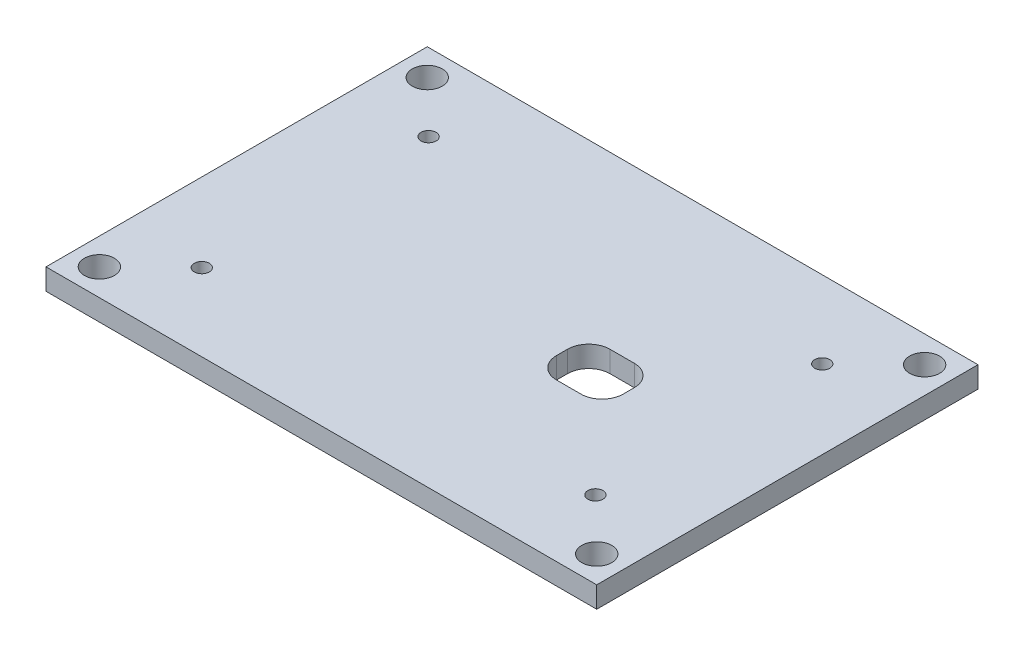
from build123d import *

# Parameters (mm, degrees)
SKETCH1_W             = 82.55
SKETCH1_H             = 57.15
BOSS_EXTRUDE1_DEPTH   = 3.175
CUT_EXTRUDE5_DEPTH    = 10
F_8_CLEARANCE_HOLE1_D = 4.4958
F_4_40_TAPPED_HOLE1_D = 2.2606


with BuildPart() as part:
    # Sketch1 → Boss-Extrude1 (new body)
    with BuildSketch(Plane(origin=(0, 0, 0), x_dir=(1, 0, 0), z_dir=(0, 1, 0))):
        Rectangle(SKETCH1_W, SKETCH1_H)
    extrude(amount=BOSS_EXTRUDE1_DEPTH)

    # Sketch2 → Cut-Extrude5 (cut)
    with BuildSketch(Plane.XZ):
        with BuildLine():
            Line((8.5, 1.825), (8.5, 0.175))
            ThreePointArc((8.5, 0.175), (9.42993597, -2.07006403), (11.675, -3))
            Line((11.675, -3), (15.325, -3))
            ThreePointArc((15.325, -3), (17.57006403, -2.07006403), (18.5, 0.175))
            Line((18.5, 0.175), (18.5, 1.825))
            ThreePointArc((18.5, 1.825), (17.57006403, 4.07006403), (15.325, 5))
            Line((15.325, 5), (11.675, 5))
            ThreePointArc((11.675, 5), (9.42993597, 4.07006403), (8.5, 1.825))
        make_face()
    extrude(amount=-CUT_EXTRUDE5_DEPTH, mode=Mode.SUBTRACT)

    # #8 Clearance Hole1 (through all)
    with Locations(Plane(origin=(0, 0, 0), x_dir=(-1, 0, 0), z_dir=(0, -1, 0))):
        with Locations((-37.275, 24.575), (37.275, 24.575), (37.275, -24.575), (-37.275, -24.575)):
            Hole(F_8_CLEARANCE_HOLE1_D / 2)

    # #4-40 Tapped Hole1 (through all)
    with Locations(Plane(origin=(0, 3.175, 0), x_dir=(1, 0, 0), z_dir=(0, 1, 0))):
        with Locations((-29.5, -17), (-29.5, 17), (29.5, 17), (29.5, -17)):
            Hole(F_4_40_TAPPED_HOLE1_D / 2)


solid = part.part
